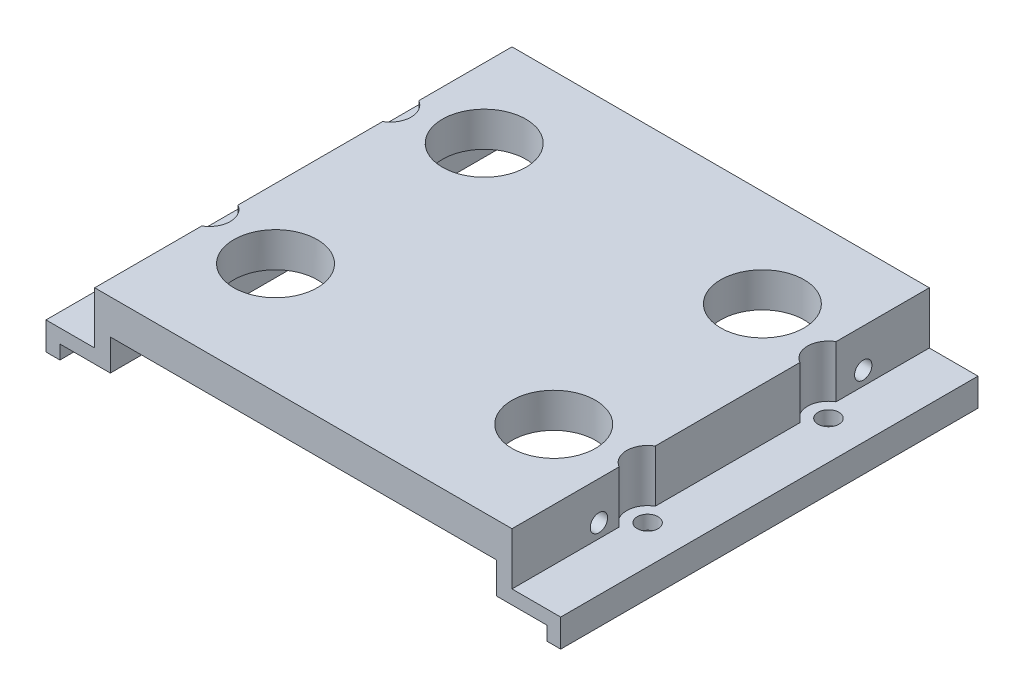
from build123d import *

# Parameters (mm, degrees)
BOSS_EXTRUDE1_DEPTH             = 30
M3_TAPPED_HOLE1_D               = 2.5
M3_TAPPED_HOLE1_DEPTH           = 5
M3_TAPPED_HOLE1_TIP             = 0.751075774
M3_TAPPED_HOLE1_ON_FACE_2_D     = 2.5
M3_TAPPED_HOLE1_ON_FACE_2_DEPTH = 5
M3_TAPPED_HOLE1_ON_FACE_2_TIP   = 0.751075774
SKETCH7_R                       = 1.5
CUT_EXTRUDE2_DEPTH              = 5
SKETCH8_R                       = 3
CUT_EXTRUDE3_DEPTH              = 7.5
SKETCH2_R                       = 6
CUT_EXTRUDE1_DEPTH              = 12.5


with BuildPart() as part:
    # Sketch1 → Boss-Extrude1 (new body, symmetric)
    with BuildSketch(Plane.XY):
        Polygon((0, 0), (0, -2), (-2, -2), (-2, 2), (5, 2), (5, 9.5), (65, 9.5), (65, 2), (72, 2), (72, -2), (70, -2), (70, 0), (62.75, 0), (62.75, 4.5), (7.25, 4.5), (7.25, 0), align=None)
    extrude(amount=BOSS_EXTRUDE1_DEPTH, both=True)

    # M3 Tapped Hole1
    with Locations(Plane(origin=(5, 4, 17.50098961), x_dir=(0, -1, 0), z_dir=(-1, 0, 0))):
        with Locations((0, 0), (0, -38)):
            Hole(M3_TAPPED_HOLE1_D / 2, depth=M3_TAPPED_HOLE1_DEPTH)
            with Locations((0, 0, -(M3_TAPPED_HOLE1_DEPTH + M3_TAPPED_HOLE1_TIP / 2))):  # 118° drill point
                Cone(0, M3_TAPPED_HOLE1_D / 2, M3_TAPPED_HOLE1_TIP, mode=Mode.SUBTRACT)

    # M3 Tapped Hole1 on face 2
    with Locations(Plane(origin=(65, 4, 17.50098961), x_dir=(0, 0, 1), z_dir=(1, 0, 0))):
        with Locations((0, 0), (-38, 0)):
            Hole(M3_TAPPED_HOLE1_ON_FACE_2_D / 2, depth=M3_TAPPED_HOLE1_ON_FACE_2_DEPTH)
            with Locations((0, 0, -(M3_TAPPED_HOLE1_ON_FACE_2_DEPTH + M3_TAPPED_HOLE1_ON_FACE_2_TIP / 2))):  # 118° drill point
                Cone(0, M3_TAPPED_HOLE1_ON_FACE_2_D / 2, M3_TAPPED_HOLE1_ON_FACE_2_TIP, mode=Mode.SUBTRACT)

    # Sketch7 → Cut-Extrude2 (cut, through all)
    with BuildSketch(Plane(origin=(0, 2, 0), x_dir=(1, 0, 0), z_dir=(0, 1, 0))):
        with Locations((3.5, 14)):
            Circle(SKETCH7_R)
        with Locations((66.5, 14)):
            Circle(SKETCH7_R)
        with Locations((3.5, -12)):
            Circle(SKETCH7_R)
        with Locations((66.5, -12)):
            Circle(SKETCH7_R)
    extrude(amount=-CUT_EXTRUDE2_DEPTH, mode=Mode.SUBTRACT)

    # Sketch8 → Cut-Extrude3 (cut)
    with BuildSketch(Plane(origin=(0, 9.5, 0), x_dir=(1, 0, 0), z_dir=(0, 1, 0))):
        with Locations((3.5, 14)):
            Circle(SKETCH8_R)
        with Locations((3.5, -12)):
            Circle(SKETCH8_R)
        with Locations((66.5, 14)):
            Circle(SKETCH8_R)
        with Locations((66.5, -12)):
            Circle(SKETCH8_R)
    extrude(amount=-CUT_EXTRUDE3_DEPTH, mode=Mode.SUBTRACT)

    # Sketch2 → Cut-Extrude1 (cut, through all)
    with BuildSketch(Plane(origin=(0, 9.5, 0), x_dir=(1, 0, 0), z_dir=(0, 1, 0))):
        with Locations((15, 16)):
            Circle(SKETCH2_R)
        with Locations((55, 16)):
            Circle(SKETCH2_R)
        with Locations((15, -14)):
            Circle(SKETCH2_R)
        with Locations((55, -14)):
            Circle(SKETCH2_R)
    extrude(amount=-CUT_EXTRUDE1_DEPTH, mode=Mode.SUBTRACT)


solid = part.part
